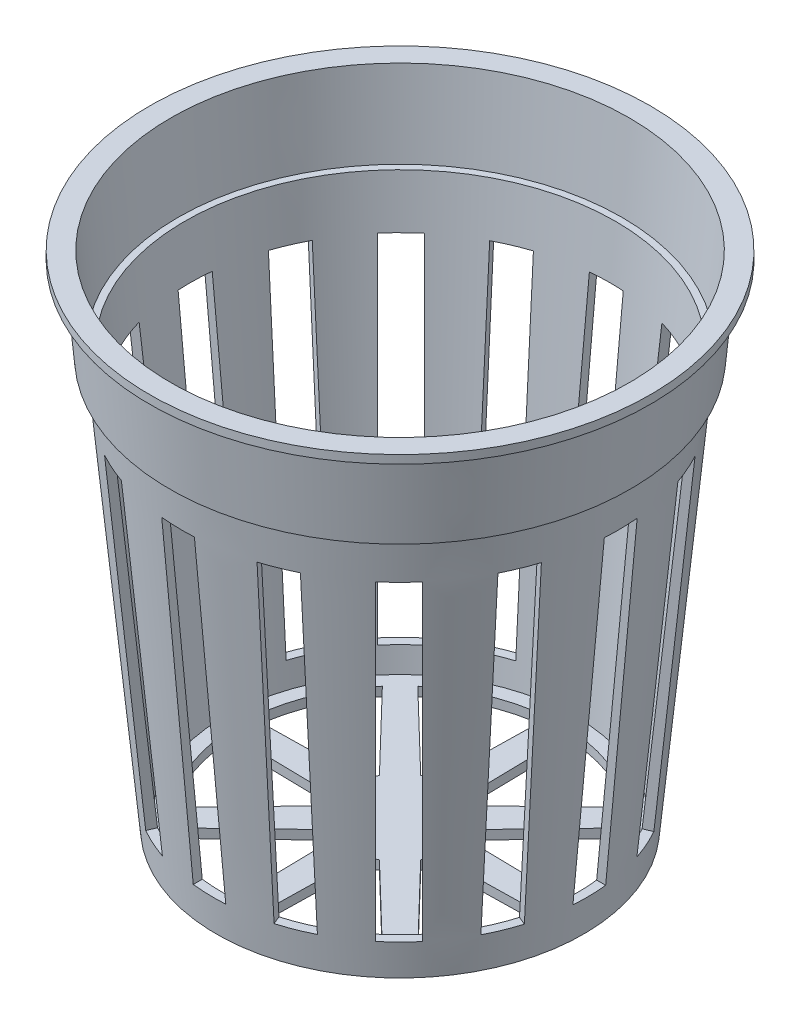
from build123d import *

# Parameters (mm, degrees)
CORTAR_EXTRUIR2_DEPTH = 112
CROQUIS11_W           = 4
CROQUIS11_H           = 16.808089165
CROQUIS11_W_2         = 16.808089165
CROQUIS11_H_2         = 4
CORTAR_EXTRUIR3_DEPTH = 40


with BuildPart() as part:
    # Croquis1 → Revolución1 (revolve)
    with BuildSketch(Plane.XY):
        Polygon((-27.489415048, 0), (-30, 0), (-30, -1), (-28.5, -1), (-27.603353842, -11), (-26.603353842, -11), (-22, -60), (0, -60), (0, -58.902540381), (-21.020029368, -58.902540381), (-25.804439037, -9.881949504), (-26.603353842, -9.881949504), align=None)
    revolve(axis=Axis((0, -60, 0), (0, 1, 0)))

    # Croquis9 → Cortar-Extruir2 (cut)
    with BuildSketch(Plane(origin=(0, 0, 0), x_dir=(1, 0, 0), z_dir=(0, 1, 0))):
        with BuildLine():
            Line((-1.75, 6.184718181), (-1.5, 19.300075922))
            ThreePointArc((-1.5, 19.300075922), (-7.408092304, 17.884716912), (-12.58655439, 14.707874734))
            Line((-12.58655439, 14.707874734), (-3.135819299, 5.610693033))
            ThreePointArc((-3.135819299, 5.610693033), (-2.459712132, 5.938270389), (-1.75, 6.184718181))
        make_face()
        with BuildLine():
            Line((3.135819299, 5.610693033), (12.58655439, 14.707874734))
            ThreePointArc((12.58655439, 14.707874734), (7.408092304, 17.884716912), (1.5, 19.300075922))
            Line((1.5, 19.300075922), (1.75, 6.184718181))
            ThreePointArc((1.75, 6.184718181), (2.459712132, 5.938270389), (3.135819299, 5.610693033))
        make_face()
        with BuildLine():
            Line((6.184718181, 1.75), (19.300075922, 1.5))
            ThreePointArc((19.300075922, 1.5), (17.884716912, 7.408092304), (14.707874734, 12.58655439))
            Line((14.707874734, 12.58655439), (5.610693033, 3.135819299))
            ThreePointArc((5.610693033, 3.135819299), (5.938270389, 2.459712132), (6.184718181, 1.75))
        make_face()
        with BuildLine():
            Line((5.610693033, -3.135819299), (14.707874734, -12.58655439))
            ThreePointArc((14.707874734, -12.58655439), (17.884716912, -7.408092304), (19.300075922, -1.5))
            Line((19.300075922, -1.5), (6.184718181, -1.75))
            ThreePointArc((6.184718181, -1.75), (5.938270389, -2.459712132), (5.610693033, -3.135819299))
        make_face()
        with BuildLine():
            Line((1.75, -6.184718181), (1.5, -19.300075922))
            ThreePointArc((1.5, -19.300075922), (7.408092304, -17.884716912), (12.58655439, -14.707874734))
            Line((12.58655439, -14.707874734), (3.135819299, -5.610693033))
            ThreePointArc((3.135819299, -5.610693033), (2.459712132, -5.938270389), (1.75, -6.184718181))
        make_face()
        with BuildLine():
            Line((-3.135819299, -5.610693033), (-12.58655439, -14.707874734))
            ThreePointArc((-12.58655439, -14.707874734), (-7.408092304, -17.884716912), (-1.5, -19.300075922))
            Line((-1.5, -19.300075922), (-1.75, -6.184718181))
            ThreePointArc((-1.75, -6.184718181), (-2.459712132, -5.938270389), (-3.135819299, -5.610693033))
        make_face()
        with BuildLine():
            Line((-6.184718181, -1.75), (-19.300075922, -1.5))
            ThreePointArc((-19.300075922, -1.5), (-17.884716912, -7.408092304), (-14.707874734, -12.58655439))
            Line((-14.707874734, -12.58655439), (-5.610693033, -3.135819299))
            ThreePointArc((-5.610693033, -3.135819299), (-5.938270389, -2.459712132), (-6.184718181, -1.75))
        make_face()
        with BuildLine():
            Line((-5.610693033, 3.135819299), (-14.707874734, 12.58655439))
            ThreePointArc((-14.707874734, 12.58655439), (-17.884716912, 7.408092304), (-19.300075922, 1.5))
            Line((-19.300075922, 1.5), (-6.184718181, 1.75))
            ThreePointArc((-6.184718181, 1.75), (-5.938270389, 2.459712132), (-5.610693033, 3.135819299))
        make_face()
    extrude(amount=-CORTAR_EXTRUIR2_DEPTH, mode=Mode.SUBTRACT)

    # Croquis11 → Cortar-Extruir3 (cut)
    with BuildSketch(Plane(origin=(0, -56, 0), x_dir=(1, 0, 0), z_dir=(0, 1, 0))):
        with Locations((-0.4, 22.457977408)):
            Rectangle(CROQUIS11_W, CROQUIS11_H)
        Polygon((9.372703114, 29.283983817), (2.940525861, 13.755334257), (6.636043991, 12.224600528), (13.068221244, 27.753250088), align=None)
        Polygon((19.645373498, 23.320848212), (7.760259671, 11.435734384), (10.588686796, 8.60730726), (22.473800623, 20.492421087), align=None)
        Polygon((26.854090209, 13.880448514), (11.325440649, 7.448271261), (12.856174379, 3.75275313), (28.384823939, 10.184930384), align=None)
        with Locations((21.497346893, 0.4)):
            Rectangle(CROQUIS11_W_2, CROQUIS11_H_2)
        Polygon((28.323353302, -9.372703114), (12.794703741, -2.940525861), (11.263970012, -6.636043991), (26.792619572, -13.068221244), align=None)
        Polygon((22.360217696, -19.645373498), (10.475103869, -7.760259671), (7.646676744, -10.588686796), (19.531790571, -22.473800623), align=None)
        Polygon((12.919817998, -26.854090209), (6.487640745, -11.325440649), (2.792122615, -12.856174379), (9.224299868, -28.384823939), align=None)
        with Locations((-0.560630516, -21.497346893)):
            Rectangle(CROQUIS11_W, CROQUIS11_H)
        Polygon((-10.333333629, -28.323353302), (-3.901156376, -12.794703741), (-7.596674506, -11.263970012), (-14.028851759, -26.792619572), align=None)
        Polygon((-20.606004014, -22.360217696), (-8.720890187, -10.475103869), (-11.549317311, -7.646676744), (-23.434431139, -19.531790571), align=None)
        Polygon((-27.814720725, -12.919817998), (-12.286071165, -6.487640745), (-13.816804894, -2.792122615), (-29.345454454, -9.224299868), align=None)
        with Locations((-22.457977408, 0.560630516)):
            Rectangle(CROQUIS11_W_2, CROQUIS11_H_2)
        Polygon((-29.283983817, 10.333333629), (-13.755334257, 3.901156376), (-12.224600528, 7.596674506), (-27.753250088, 14.028851759), align=None)
        Polygon((-23.320848212, 20.606004014), (-11.435734384, 8.720890187), (-8.60730726, 11.549317311), (-20.492421087, 23.434431139), align=None)
        Polygon((-13.880448514, 27.814720725), (-7.448271261, 12.286071165), (-3.75275313, 13.816804894), (-10.184930384, 29.345454454), align=None)
    extrude(amount=CORTAR_EXTRUIR3_DEPTH, mode=Mode.SUBTRACT)


solid = part.part
